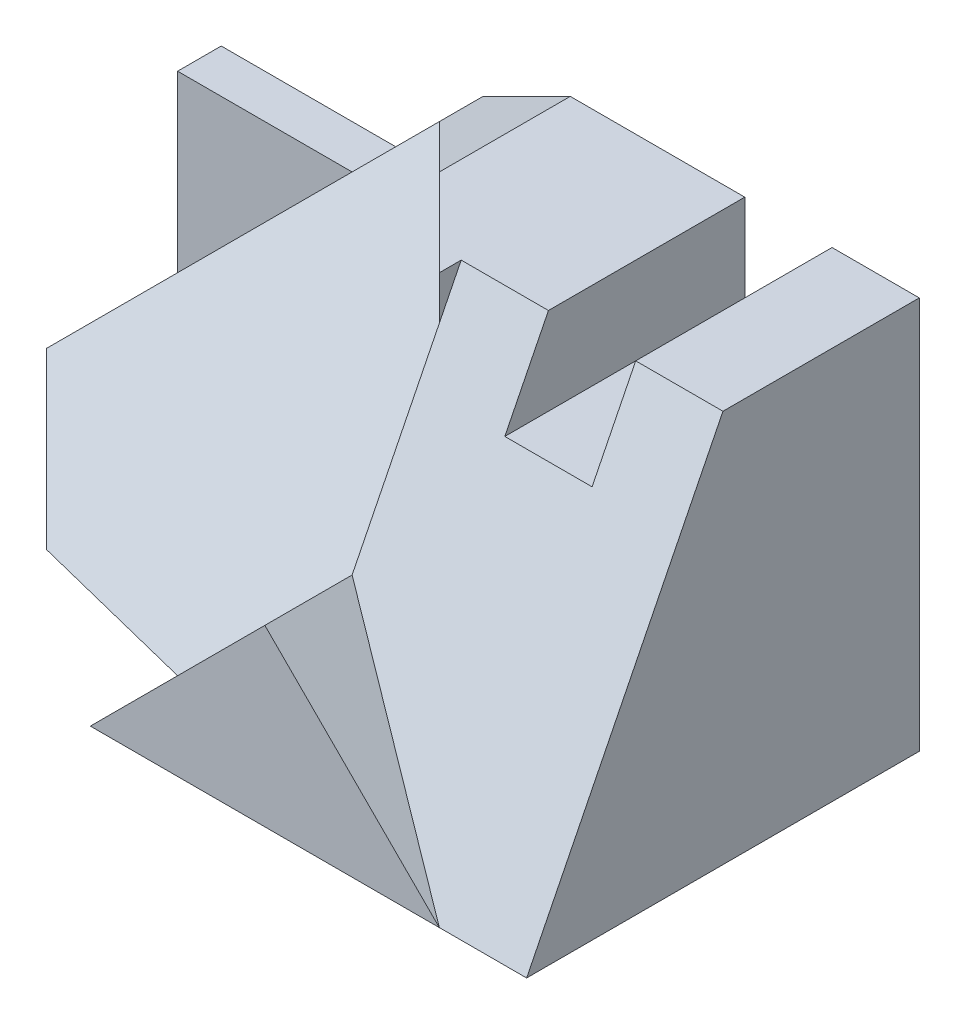
from build123d import *

# Parameters (mm, degrees)
BOSS_EXTRUDE1_DEPTH = 9
SKETCH2_W           = 2
SKETCH2_H           = 2
CUT_EXTRUDE1_DEPTH  = 9
CUT_EXTRUDE2_DEPTH  = 8
CUT_EXTRUDE3_DEPTH  = 8
CUT_EXTRUDE4_DEPTH  = 8
CUT_EXTRUDE5_DEPTH  = 8


with BuildPart() as part:
    # Sketch1 → Boss-Extrude1 (new body)
    with BuildSketch(Plane(origin=(0, 0, 0), x_dir=(1, 0, 0), z_dir=(0, 1, 0))):
        Polygon((-8, 4.5), (-8, 0.5), (-6, -1.5), (-2, -2.5), (-2, -4.5), (8, -4.5), (8, 4.5), align=None)
    extrude(amount=BOSS_EXTRUDE1_DEPTH)

    # Sketch2 → Cut-Extrude1 (cut)
    with BuildSketch(Plane.XY.offset(4.5)):
        with Locations((5, 8)):
            Rectangle(SKETCH2_W, SKETCH2_H)
        Polygon((-8, 6), (-4, 6), (-2, 8), (0, 9), (-8, 9), align=None)
        Polygon((-8, 2), (-6, 0), (-8, 0), align=None)
    extrude(amount=-CUT_EXTRUDE1_DEPTH, mode=Mode.SUBTRACT)

    # Sketch4 → Cut-Extrude2 (cut)
    with BuildSketch(Plane.XY.offset(4.5)):
        Polygon((-4, 6), (-8, 2), (-8, 6), align=None)
    extrude(amount=-CUT_EXTRUDE2_DEPTH, mode=Mode.SUBTRACT)

    # 3DSketch1 → Cut-Extrude3 (cut, along a direction that is not the sketch's normal)
    with BuildSketch(Plane(origin=(8, 0, 4.5), x_dir=(-0.5121475197315839, 0.7682212795973759, -0.3841106397986879), z_dir=(0, -0.447213595499958, -0.894427190999916))):
        Polygon((0, 0), (1.024295039, -1.717795003), (6.913991516, -2.862991672), (11.715374514, 0), (8.642489395, 5.153385009), align=None)
    extrude(amount=-CUT_EXTRUDE3_DEPTH, dir=(0, 0, -1), mode=Mode.SUBTRACT)

    # 3DSketch2 → Cut-Extrude4 (cut, along a direction that is not the sketch's normal)
    with BuildSketch(Plane(origin=(-2, 0, 4.5), x_dir=(0.5773502691896258, 0.5773502691896258, -0.5773502691896257), z_dir=(0.7071067811865476, -0.7071067811865476, 0))):
        Polygon((0, 0), (4.618802154, 3.265986324), (6.92820323, 0), (1.154700538, -1.632993162), align=None)
    extrude(amount=-CUT_EXTRUDE4_DEPTH, dir=(0, -1, 0), mode=Mode.SUBTRACT)

    # 3DSketch3 → Cut-Extrude5 (cut, along a direction that is not the sketch's normal)
    with BuildSketch(Plane(origin=(-2, 8, -3.5), x_dir=(-0.3903600291794133, -0.7807200583588266, 0.48795003647426655), z_dir=(-0.19611613513818413, 0.5883484054145521, 0.7844645405527362))):
        Polygon((0, 0), (8.490330635, -2.985680109), (10.246950766, 0), (9.173460686, 3.980906812), (3.513240263, 5.971360218), align=None)
    extrude(amount=CUT_EXTRUDE5_DEPTH, dir=(0, 1, 0), mode=Mode.SUBTRACT)


solid = part.part
